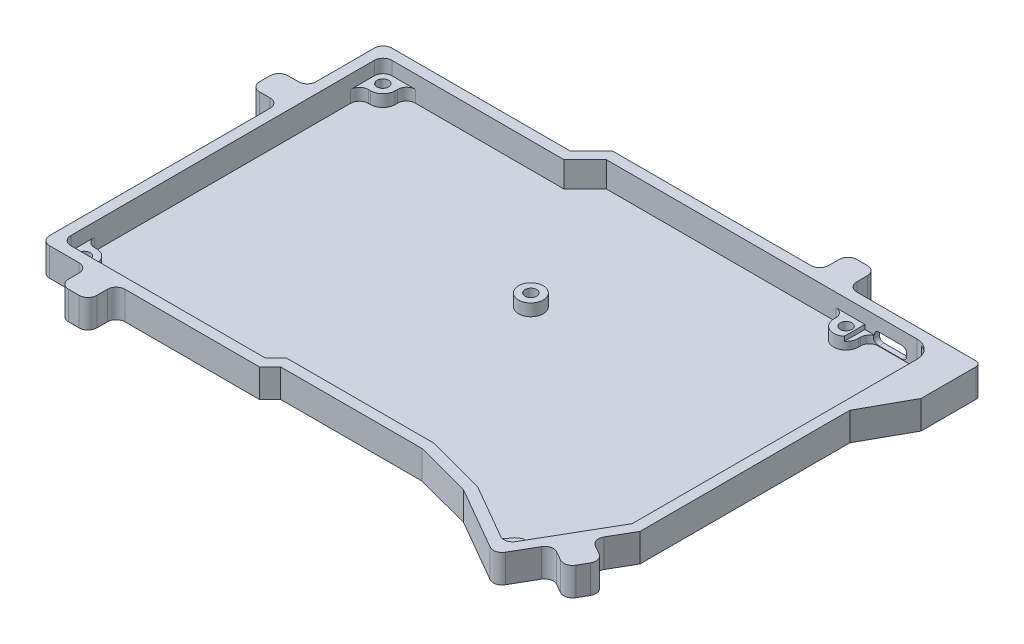
from build123d import *

# Parameters (mm, degrees)
BOSS_EXTRUDE1_DEPTH  = 7.2
BOSS_EXTRUDE2_DEPTH  = 0.8
FILLET1_R            = 2.5
FILLET2_R            = 2.5
SKETCH3_R            = 3.5
BOSS_EXTRUDE3_DEPTH  = 3.4
SKETCH5_R            = 1.65
CUT_EXTRUDE1_DEPTH   = 2.5
FILLET3_R            = 2.5
CUT_EXTRUDE4_REACH   = 141.106
SKETCH8_W            = 9.14
SKETCH8_H            = 3.36
FILLET5_R            = 1.3
CUT_EXTRUDE5_DEPTH   = 1.6
CUT_EXTRUDE6_REACH   = 170.765
SKETCH10_W           = 12
SKETCH10_H           = 7.2
BOSS_EXTRUDE4_DEPTH  = 5.2
SKETCH13_W           = 17
SKETCH13_H           = 8
BOSS_EXTRUDE5_DEPTH  = 2
CUT_EXTRUDE7_REACH   = 143.675
SKETCH14_R           = 2.6
CUT_EXTRUDE8_START   = -7.2
CUT_EXTRUDE8_DEPTH   = 7.2
BOSS_EXTRUDE6_DEPTH  = 8
BOSS_EXTRUDE8_DEPTH  = 0.8
FILLET6_R            = 1
CHAMFER1_SIZE        = 10
CHAMFER1_SIZE2       = 5.543090515
FILLET7_R            = 5
FILLET8_R            = 1.5
SKETCH18_W           = 8
SKETCH18_H           = 8
BOSS_EXTRUDE9_DEPTH  = 8
SKETCH19_W           = 8
SKETCH19_H           = 8
BOSS_EXTRUDE10_DEPTH = 8
SKETCH20_W           = 8
SKETCH20_H           = 8
BOSS_EXTRUDE11_DEPTH = 8
SKETCH21_W           = 8
SKETCH21_H           = 8
BOSS_EXTRUDE12_DEPTH = 8
FILLET11_R           = 2.5
SKETCH22_R           = 2.2
CUT_EXTRUDE9_DEPTH   = 6
SKETCH23_W           = 3.505
SKETCH23_H           = 6.6
CUT_EXTRUDE10_DEPTH  = 1.25


with BuildPart() as part:
    # Sketch1 → Boss-Extrude1 (new body)
    with BuildSketch(Plane(origin=(0, 0, 0), x_dir=(1, 0, 0), z_dir=(0, 1, 0))):
        Polygon((78.125, -37.9381301), (62.908489388, -64.283910205), (42.956179643, -52.779359478), (26.916138362, -48.5), (-13.175252532, -48.5), (-16.175252532, -51.5), (-78.125, -51.5), (-78.125, 45.5), (-25.074747468, 45.5), (-19.074747468, 51.5), (78.125, 51.5), align=None)
        Polygon((75.125, -37.134018586), (61.80999823, -60.187537075), (44.11188212, -49.982759925), (27.309448337, -45.5), (-14.417893219, -45.5), (-17.417893219, -48.5), (-75.125, -48.5), (-75.125, 42.5), (-23.832106781, 42.5), (-17.832106781, 48.5), (75.125, 48.5), align=None, mode=Mode.SUBTRACT)
    extrude(amount=BOSS_EXTRUDE1_DEPTH)

    # Sketch2 → Boss-Extrude2 (add)
    with BuildSketch(Plane.XZ):
        Polygon((78.125, -51.5), (78.125, 37.9381301), (62.908489388, 64.283910205), (42.956179643, 52.779359478), (26.916138362, 48.5), (-13.175252532, 48.5), (-16.175252532, 51.5), (-78.125, 51.5), (-78.125, -45.5), (-25.074747468, -45.5), (-19.074747468, -51.5), align=None)
    extrude(amount=BOSS_EXTRUDE2_DEPTH)

    # Fillet1
    fillet1_edges = [part.edges().sort_by_distance(p)[0] for p in [
        (-75.125, 3.6, -42.5),
        (-75.125, 3.6, 48.5),
        (61.80999823, 3.6, 60.187537075),
    ]]
    fillet(fillet1_edges, radius=FILLET1_R)

    # Fillet2
    fillet2_edges = [part.edges().sort_by_distance(p)[0] for p in [
        (62.908489388, 3.2, 64.283910205),
        (-78.125, 3.2, 51.5),
        (-78.125, 3.2, -45.5),
    ]]
    fillet(fillet2_edges, radius=FILLET2_R)

    # Sketch3 → Boss-Extrude3 (add)
    with BuildSketch(Plane(origin=(0, 0, 0), x_dir=(1, 0, 0), z_dir=(0, 1, 0))):
        with BuildLine():
            ThreePointArc((-68.5, -45.3), (-69.525126266, -42.825126266), (-72, -41.8))
            ThreePointArc((-72, -41.8), (-73.834848074, -42.319508003), (-75.125, -43.723809973))
            Line((-75.125, -43.723809973), (-75.125, -46))
            ThreePointArc((-75.125, -46), (-74.392766953, -47.767766953), (-72.625, -48.5))
            Line((-72.625, -48.5), (-70.582255312, -48.5))
            ThreePointArc((-70.582255312, -48.5), (-69.066392459, -47.208912464), (-68.5, -45.3))
        make_face()
        with BuildLine():
            Line((-75.125, -46), (-75.125, -43.723809973))
            ThreePointArc((-75.125, -43.723809973), (-74.536075308, -47.712119821), (-70.582255312, -48.5))
            Line((-70.582255312, -48.5), (-72.625, -48.5))
            ThreePointArc((-72.625, -48.5), (-74.392766953, -47.767766953), (-75.125, -46))
        make_face()
        with BuildLine():
            Line((-72, -41.8), (-75.125, -41.8))
            Line((-75.125, -41.8), (-75.125, -43.723809973))
            ThreePointArc((-75.125, -43.723809973), (-73.834848074, -42.319508003), (-72, -41.8))
        make_face()
        with BuildLine():
            ThreePointArc((-70.582255312, 42.5), (-69.066392459, 41.208912464), (-68.5, 39.3))
            Line((-68.5, 39.3), (-68.5, 42.5))
            Line((-68.5, 42.5), (-70.582255312, 42.5))
        make_face()
        with BuildLine():
            ThreePointArc((-72, 35.8), (-69.525126266, 36.825126266), (-68.5, 39.3))
            ThreePointArc((-68.5, 39.3), (-69.066392459, 41.208912464), (-70.582255312, 42.5))
            Line((-70.582255312, 42.5), (-72.625, 42.5))
            ThreePointArc((-72.625, 42.5), (-74.392766953, 41.767766953), (-75.125, 40))
            Line((-75.125, 40), (-75.125, 37.723809973))
            ThreePointArc((-75.125, 37.723809973), (-73.834848074, 36.319508003), (-72, 35.8))
        make_face()
        with BuildLine():
            Line((-72.625, 42.5), (-70.582255312, 42.5))
            ThreePointArc((-70.582255312, 42.5), (-74.536075308, 41.712119821), (-75.125, 37.723809973))
            Line((-75.125, 37.723809973), (-75.125, 40))
            ThreePointArc((-75.125, 40), (-74.392766953, 41.767766953), (-72.625, 42.5))
        make_face()
        with BuildLine():
            Line((-75.125, 35.8), (-72, 35.8))
            ThreePointArc((-72, 35.8), (-73.834848074, 36.319508003), (-75.125, 37.723809973))
            Line((-75.125, 37.723809973), (-75.125, 35.8))
        make_face()
        with Locations(Location((0.325, 8.92, 0), (0, 0, 90))):
            Circle(SKETCH3_R)
        with BuildLine():
            ThreePointArc((54.769807681, 48.5), (53.145, 48.9), (51.520192319, 48.5))
            Line((51.520192319, 48.5), (54.769807681, 48.5))
        make_face()
        with BuildLine():
            Line((54.769807681, 48.5), (51.520192319, 48.5))
            ThreePointArc((51.520192319, 48.5), (50.150269054, 47.21151499), (49.645, 45.4))
            ThreePointArc((49.645, 45.4), (53.145, 41.9), (56.645, 45.4))
            ThreePointArc((56.645, 45.4), (56.139730946, 47.21151499), (54.769807681, 48.5))
        make_face()
        with BuildLine():
            Line((56.645, 48.5), (54.769807681, 48.5))
            ThreePointArc((54.769807681, 48.5), (56.139730946, 47.21151499), (56.645, 45.4))
            Line((56.645, 45.4), (56.645, 48.5))
        make_face()
        with BuildLine():
            Line((51.520192319, 48.5), (49.645, 48.5))
            Line((49.645, 48.5), (49.645, 45.4))
            ThreePointArc((49.645, 45.4), (50.150269054, 47.21151499), (51.520192319, 48.5))
        make_face()
        with BuildLine():
            Line((65.101251039, -54.489080642), (62.35329915, -52.901948322))
            ThreePointArc((62.35329915, -52.901948322), (63.63559788, -54.183168367), (64.105, -55.934018586))
            ThreePointArc((64.105, -55.934018586), (64.101720652, -56.085493606), (64.091888753, -56.236684774))
            Line((64.091888753, -56.236684774), (65.101251039, -54.489080642))
        make_face()
        with BuildLine():
            ThreePointArc((64.105, -55.934018586), (63.63559788, -54.183168367), (62.35329915, -52.901948322))
            ThreePointArc((62.35329915, -52.901948322), (59.69723674, -52.553786957), (57.572929736, -54.185719436))
            ThreePointArc((57.572929736, -54.185719436), (57.105435608, -55.989236911), (57.629596912, -57.777107424))
            Line((57.629596912, -57.777107424), (59.645803824, -58.939657274))
            ThreePointArc((59.645803824, -58.939657274), (61.542115723, -59.188578919), (63.059447202, -58.024248216))
            Line((63.059447202, -58.024248216), (64.091888753, -56.236684774))
            ThreePointArc((64.091888753, -56.236684774), (64.101720652, -56.085493606), (64.105, -55.934018586))
        make_face()
        with BuildLine():
            ThreePointArc((57.629596912, -57.777107424), (61.416560153, -59.338628713), (64.091888753, -56.236684774))
            Line((64.091888753, -56.236684774), (63.059447202, -58.024248216))
            ThreePointArc((63.059447202, -58.024248216), (61.542115723, -59.188578919), (59.645803824, -58.939657274))
            Line((59.645803824, -58.939657274), (57.629596912, -57.777107424))
        make_face()
        with BuildLine():
            Line((57.572929736, -54.185719436), (56.032960832, -56.856483145))
            Line((56.032960832, -56.856483145), (57.629596912, -57.777107424))
            ThreePointArc((57.629596912, -57.777107424), (57.105435608, -55.989236911), (57.572929736, -54.185719436))
        make_face()
        with BuildLine():
            Line((-68.5, -48.5), (-68.5, -45.3))
            ThreePointArc((-68.5, -45.3), (-69.066392459, -47.208912464), (-70.582255312, -48.5))
            Line((-70.582255312, -48.5), (-68.5, -48.5))
        make_face()
    extrude(amount=BOSS_EXTRUDE3_DEPTH)

    # Sketch5 → Cut-Extrude1 (cut)
    with BuildSketch(Plane(origin=(0, 3.4, 0), x_dir=(1, 0, 0), z_dir=(0, 1, 0))):
        with Locations(Location((-72, 39.3, 0), (0, 0, 270))):
            Circle(SKETCH5_R)
        with Locations(Location((0.325, 8.92, 0), (0, 0, 270))):
            Circle(SKETCH5_R)
        with Locations(Location((53.145, 45.4, 0), (0, 0, 270))):
            Circle(SKETCH5_R)
        with Locations(Location((60.605, -55.934018586, 0), (0, 0, 270))):
            Circle(SKETCH5_R)
        with Locations(Location((-72, -45.3, 0), (0, 0, 270))):
            Circle(SKETCH5_R)
    extrude(amount=-CUT_EXTRUDE1_DEPTH, mode=Mode.SUBTRACT)

    # Fillet3
    fillet3_edges = [part.edges().sort_by_distance(p)[0] for p in [
        (-68.5, 1.7, -42.5),
        (-75.125, 1.7, -35.8),
        (56.645, 1.7, -48.5),
        (49.645, 1.7, -48.5),
        (65.101251039, 1.7, 54.489080642),
        (56.032960832, 1.7, 56.856483145),
        (-68.5, 1.7, 48.5),
        (-75.125, 1.7, 41.8),
    ]]
    fillet(fillet3_edges, radius=FILLET3_R)

    # Sketch8 → Cut-Extrude4 (cut, up to next)
    with BuildSketch(Plane(origin=(0, 0, -51.5), x_dir=(-1, 0, 0), z_dir=(0, 0, -1)), mode=Mode.PRIVATE) as cut_extrude4_sk1:
        with Locations((-62.66, 1.82)):
            Rectangle(SKETCH8_W, SKETCH8_H)
    cut_extrude4_tool1 = extrude(cut_extrude4_sk1.sketch, amount=-CUT_EXTRUDE4_REACH, mode=Mode.PRIVATE) & part.part
    add(cut_extrude4_tool1.solids().sort_by_distance((62.66, 1.82, -51.5))[0], mode=Mode.SUBTRACT)

    # Fillet5
    fillet5_edges = [part.edges().sort_by_distance(p)[0] for p in [
        (67.23, 0.14, -50),
        (58.09, 0.14, -49.883244788),
        (58.09, 3.5, -50),
        (67.23, 3.5, -50),
    ]]
    fillet(fillet5_edges, radius=FILLET5_R)

    # Sketch9 → Cut-Extrude5 (cut)
    with BuildSketch(Plane(origin=(0, 0, -51.5), x_dir=(-1, 0, 0), z_dir=(0, 0, -1))):
        with BuildLine():
            ThreePointArc((-65.93, 6), (-68.617005769, 4.887005769), (-69.73, 2.2))
            Line((-69.73, 2.2), (-69.73, 1.44))
            ThreePointArc((-69.73, 1.44), (-69.542786505, 0.261961942), (-68.999592807, -0.8))
            Line((-68.999592807, -0.8), (-56.320407193, -0.8))
            ThreePointArc((-56.320407193, -0.8), (-55.777213495, 0.261961942), (-55.59, 1.44))
            Line((-55.59, 1.44), (-55.59, 2.2))
            ThreePointArc((-55.59, 2.2), (-56.702994231, 4.887005769), (-59.39, 6))
            Line((-59.39, 6), (-65.93, 6))
        make_face()
        with BuildLine():
            ThreePointArc((-68.999592807, -0.8), (-69.542786505, 0.261961942), (-69.73, 1.44))
            Line((-69.73, 1.44), (-69.73, -0.8))
            Line((-69.73, -0.8), (-68.999592807, -0.8))
        make_face()
        with BuildLine():
            Line((-56.320407193, -0.8), (-68.999592807, -0.8))
            ThreePointArc((-68.999592807, -0.8), (-67.651627137, -1.947624536), (-65.93, -2.36))
            Line((-65.93, -2.36), (-59.39, -2.36))
            ThreePointArc((-59.39, -2.36), (-57.668372863, -1.947624536), (-56.320407193, -0.8))
        make_face()
        with BuildLine():
            ThreePointArc((-55.59, 1.44), (-55.777213495, 0.261961942), (-56.320407193, -0.8))
            Line((-56.320407193, -0.8), (-55.59, -0.8))
            Line((-55.59, -0.8), (-55.59, 1.44))
        make_face()
    extrude(amount=-CUT_EXTRUDE5_DEPTH, mode=Mode.SUBTRACT)

    # Sketch10 → Cut-Extrude6 (cut, up to next)
    with BuildSketch(Plane(origin=(78.125, 0, 0), x_dir=(0, 0, -1), z_dir=(1, 0, 0)), mode=Mode.PRIVATE) as cut_extrude6_sk1:
        with Locations((42.5, 3.6)):
            Rectangle(SKETCH10_W, SKETCH10_H)
    cut_extrude6_tool1 = extrude(cut_extrude6_sk1.sketch, amount=-CUT_EXTRUDE6_REACH, mode=Mode.PRIVATE) & part.part
    add(cut_extrude6_tool1.solids().sort_by_distance((78.125, 3.6, -42.5))[0], mode=Mode.SUBTRACT)

    # Sketch12 → Boss-Extrude4 (add)
    with BuildSketch(Plane(origin=(78.125, 0, 0), x_dir=(0, 0, -1), z_dir=(1, 0, 0))):
        Polygon((36.5, 7.2), (34.5, 7.2), (34.5, -0.8), (51.5, -0.8), (51.5, 7.2), (49.5, 7.2), (49.5, 0), (36.5, 0), align=None)
    extrude(amount=BOSS_EXTRUDE4_DEPTH)

    # Sketch13 → Boss-Extrude5 (add)
    with BuildSketch(Plane(origin=(83.325, 0, 0), x_dir=(0, 0, -1), z_dir=(1, 0, 0))):
        with Locations((43, 3.2)):
            Rectangle(SKETCH13_W, SKETCH13_H)
    extrude(amount=BOSS_EXTRUDE5_DEPTH)

    # Sketch14 → Cut-Extrude7 (cut, up to next)
    with BuildSketch(Plane.XY.offset(-49.5), mode=Mode.PRIVATE) as cut_extrude7_sk1:
        with Locations((80.725, 3.1)):
            Circle(SKETCH14_R)
    cut_extrude7_tool1 = extrude(cut_extrude7_sk1.sketch, amount=-CUT_EXTRUDE7_REACH, mode=Mode.PRIVATE) & part.part
    add(cut_extrude7_tool1.solids().sort_by_distance((80.725, 3.1, -49.5))[0], mode=Mode.SUBTRACT)

    # Sketch15 → Cut-Extrude8 (cut)
    with BuildSketch(Plane(origin=(0, 7.2, 0), x_dir=(1, 0, 0), z_dir=(0, 1, 0)).offset(CUT_EXTRUDE8_START)):
        Polygon((78.125, 49.5), (78.125, 48.5), (73.125, 48.5), align=None)
    extrude(amount=CUT_EXTRUDE8_DEPTH, mode=Mode.SUBTRACT)

    # Sketch16 → Boss-Extrude6 (add)
    with BuildSketch(Plane(origin=(0, 7.2, 0), x_dir=(1, 0, 0), z_dir=(0, 1, 0))):
        Polygon((85.325, 34.5), (78.125, 34.5), (78.125, 21.5), align=None)
    extrude(amount=-BOSS_EXTRUDE6_DEPTH)

    # Sketch17 → Boss-Extrude8 (add)
    with BuildSketch(Plane(origin=(0, 7.2, 0), x_dir=(1, 0, 0), z_dir=(0, 1, 0))):
        Polygon((78.125, 49.5), (73.125, 48.5), (75.125, 48.5), (75.125, 36.5), (83.325, 36.5), (83.325, 49.5), align=None)
    extrude(amount=-BOSS_EXTRUDE8_DEPTH)

    # Fillet6
    fillet6_edges = [part.edges().sort_by_distance(p)[0] for p in [
        (83.325, 3.2, -36.5),
    ]]
    fillet(fillet6_edges, radius=FILLET6_R)

    # Chamfer1
    chamfer1_edges = [part.edges().sort_by_distance(p)[0] for p in [
        (75.125, 3.2, -36.5),
    ]]
    chamfer1_side = [part.faces().sort_by_distance(p)[0] for p in [
        (75.125, 3.656913664, -0.44451348),
    ]]
    chamfer(chamfer1_edges, length=CHAMFER1_SIZE, length2=CHAMFER1_SIZE2, reference=chamfer1_side[0])

    # Fillet7
    fillet7_edges = [part.edges().sort_by_distance(p)[0] for p in [
        (75.125, 6.8, -48.5),
    ]]
    fillet(fillet7_edges, radius=FILLET7_R)

    # Fillet8
    fillet8_edges = [part.edges().sort_by_distance(p)[0] for p in [
        (85.325, 3.2, -51.5),
    ]]
    fillet(fillet8_edges, radius=FILLET8_R)

    # Sketch18 → Boss-Extrude9 (add)
    with BuildSketch(Plane(origin=(75.013447099, 0, 43.325455131), x_dir=(0.500142166534936, 0, -0.8659433083370645), z_dir=(0.8659433083370645, 0, 0.500142166534936))):
        with Locations((-7.741754602, 3.2)):
            Rectangle(SKETCH18_W, SKETCH18_H)
    extrude(amount=BOSS_EXTRUDE9_DEPTH)

    # Sketch19 → Boss-Extrude10 (add)
    with BuildSketch(Plane(origin=(0, 0, -51.5), x_dir=(-1, 0, 0), z_dir=(0, 0, -1))):
        with Locations((-43.59, 3.2)):
            Rectangle(SKETCH19_W, SKETCH19_H)
    extrude(amount=BOSS_EXTRUDE10_DEPTH)

    # Sketch20 → Boss-Extrude11 (add)
    with BuildSketch(Plane.XY.offset(51.5)):
        with Locations((-60.762563133, 3.2)):
            Rectangle(SKETCH20_W, SKETCH20_H)
    extrude(amount=BOSS_EXTRUDE11_DEPTH)

    # Sketch21 → Boss-Extrude12 (add)
    with BuildSketch(Plane.ZY.offset(78.125)):
        with Locations((-20, 3.2)):
            Rectangle(SKETCH21_W, SKETCH21_H)
    extrude(amount=BOSS_EXTRUDE12_DEPTH)

    # Fillet11
    fillet11_edges = [part.edges().sort_by_distance(p)[0] for p in [
        (73.142037846, 3.2, 46.56560249),
        (69.140900514, 3.2, 53.493148957),
        (80.069584313, 3.2, 50.566739822),
        (76.068446981, 3.2, 57.494286289),
        (39.59, 3.2, -51.5),
        (47.59, 3.2, -51.5),
        (39.59, 3.2, -59.5),
        (47.59, 3.2, -59.5),
        (-56.762563133, 3.2, 51.5),
        (-64.762563133, 3.2, 51.5),
        (-56.762563133, 3.2, 59.5),
        (-64.762563133, 3.2, 59.5),
        (-78.125, 3.2, -16),
        (-78.125, 3.2, -24),
        (-86.125, 3.2, -16),
        (-86.125, 3.2, -24),
    ]]
    fillet(fillet11_edges, radius=FILLET11_R)

    # Sketch22 → Cut-Extrude9 (cut)
    with BuildSketch(Plane.XZ.offset(0.8)):
        with Locations(Location((43.59, -55.5, 0), (0, 0, 270))):
            Circle(SKETCH22_R)
        with Locations(Location((-82.125, -20, 0), (0, 0, 270))):
            Circle(SKETCH22_R)
        with Locations(Location((-60.762563133, 55.5, 0), (0, 0, 270))):
            Circle(SKETCH22_R)
        with Locations(Location((74.605242413, 52.029944389, 0), (0, 0, 270))):
            Circle(SKETCH22_R)
    extrude(amount=-CUT_EXTRUDE9_DEPTH, mode=Mode.SUBTRACT)

    # Sketch23 → Cut-Extrude10 (cut)
    with BuildSketch(Plane(origin=(0, 3.4, 0), x_dir=(1, 0, 0), z_dir=(0, 1, 0))):
        with Locations((57.1375, 45.2)):
            Rectangle(SKETCH23_W, SKETCH23_H)
    extrude(amount=-CUT_EXTRUDE10_DEPTH, mode=Mode.SUBTRACT)


solid = part.part
